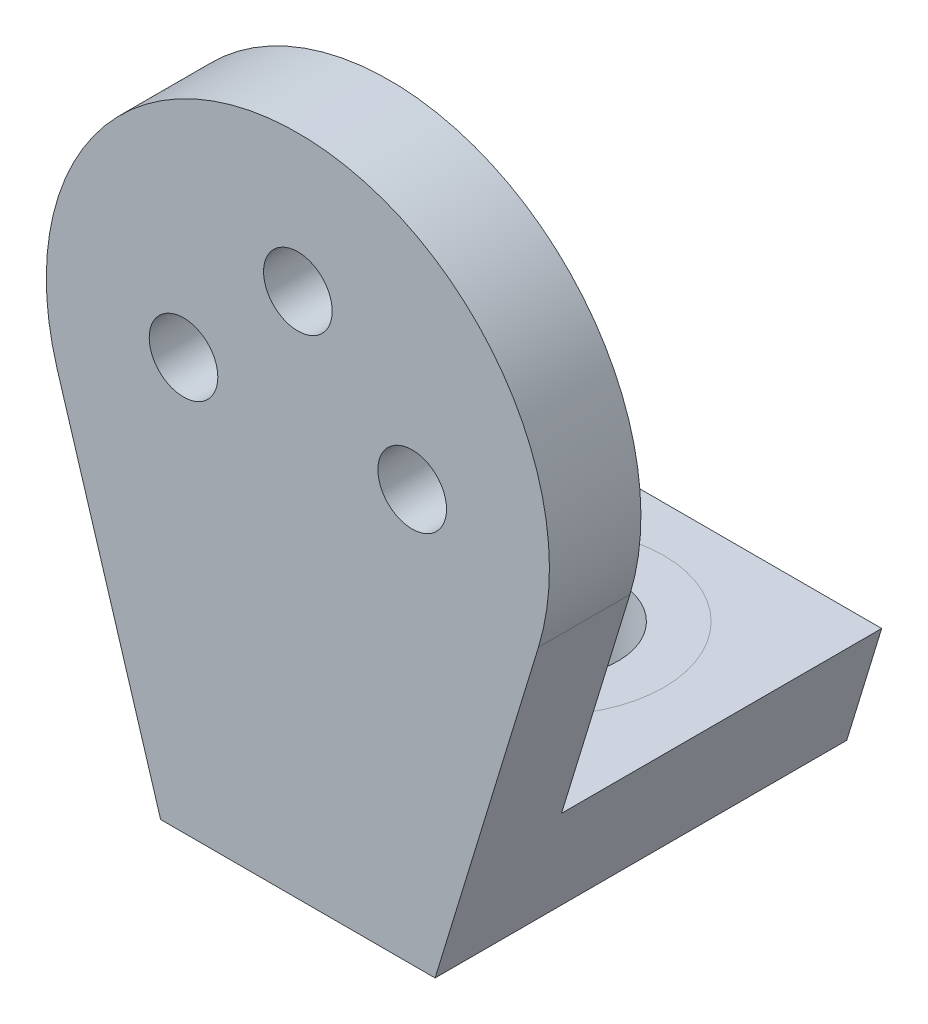
from build123d import *

# Parameters (mm, degrees)
SKETCH1_R           = 55
BOSS_EXTRUDE1_DEPTH = 20
BOSS_EXTRUDE2_DEPTH = 20
CUT_EXTRUDE2_REACH  = 22
SKETCH4_R           = 7.5
BOSS_EXTRUDE3_DEPTH = 70
CUT_EXTRUDE3_REACH  = 27
SKETCH6_R           = 15


with BuildPart() as part:
    # Sketch1 → Boss-Extrude1 (new body)
    with BuildSketch(Plane.XY):
        Circle(SKETCH1_R)
    extrude(amount=BOSS_EXTRUDE1_DEPTH)

    # Sketch2 → Boss-Extrude2 (add)
    with BuildSketch(Plane.XY.offset(20)):
        with BuildLine():
            ThreePointArc((52.597301626, -16.078677236), (0, -55), (-52.597301626, -16.078677236))
            Line((-52.597301626, -16.078677236), (-30, -90))
            Line((-30, -90), (30, -90))
            Line((30, -90), (52.597301626, -16.078677236))
        make_face()
    extrude(amount=-BOSS_EXTRUDE2_DEPTH)

    # Sketch4 → Cut-Extrude2 (cut, up to next)
    with BuildSketch(Plane(origin=(0, 0, 0), x_dir=(-1, 0, 0), z_dir=(0, 0, -1)), mode=Mode.PRIVATE) as cut_extrude2_sk1:
        with Locations((0, 25)):
            Circle(SKETCH4_R)
    cut_extrude2_tool1 = extrude(cut_extrude2_sk1.sketch, amount=-CUT_EXTRUDE2_REACH, mode=Mode.PRIVATE) & part.part
    add(cut_extrude2_tool1.solids().sort_by_distance((0, 25, 0))[0], mode=Mode.SUBTRACT)
    # Sketch4 → Cut-Extrude2 (cut, up to next)
    with BuildSketch(Plane(origin=(0, 0, 0), x_dir=(-1, 0, 0), z_dir=(0, 0, -1)), mode=Mode.PRIVATE) as cut_extrude2_sk2:
        with Locations((-25, 0)):
            Circle(SKETCH4_R)
    cut_extrude2_tool2 = extrude(cut_extrude2_sk2.sketch, amount=-CUT_EXTRUDE2_REACH, mode=Mode.PRIVATE) & part.part
    add(cut_extrude2_tool2.solids().sort_by_distance((25, 0, 0))[0], mode=Mode.SUBTRACT)
    # Sketch4 → Cut-Extrude2 (cut, up to next)
    with BuildSketch(Plane(origin=(0, 0, 0), x_dir=(-1, 0, 0), z_dir=(0, 0, -1)), mode=Mode.PRIVATE) as cut_extrude2_sk3:
        with Locations((25, 0)):
            Circle(SKETCH4_R)
    cut_extrude2_tool3 = extrude(cut_extrude2_sk3.sketch, amount=-CUT_EXTRUDE2_REACH, mode=Mode.PRIVATE) & part.part
    add(cut_extrude2_tool3.solids().sort_by_distance((-25, 0, 0))[0], mode=Mode.SUBTRACT)

    # Sketch5 → Boss-Extrude3 (add)
    with BuildSketch(Plane(origin=(0, 0, 0), x_dir=(-1, 0, 0), z_dir=(0, 0, -1))):
        Polygon((37.642348913, -65), (-37.642348913, -65), (-30, -90), (30, -90), align=None)
    extrude(amount=BOSS_EXTRUDE3_DEPTH)

    # Sketch6 → Cut-Extrude3 (cut, up to next)
    with BuildSketch(Plane(origin=(0, -65, 0), x_dir=(1, 0, 0), z_dir=(0, 1, 0)), mode=Mode.PRIVATE) as cut_extrude3_sk1:
        with Locations((0, 35)):
            Circle(SKETCH6_R)
    cut_extrude3_tool1 = extrude(cut_extrude3_sk1.sketch, amount=-CUT_EXTRUDE3_REACH, mode=Mode.PRIVATE) & part.part
    add(cut_extrude3_tool1.solids().sort_by_distance((0, -65, -35))[0], mode=Mode.SUBTRACT)


solid = part.part
